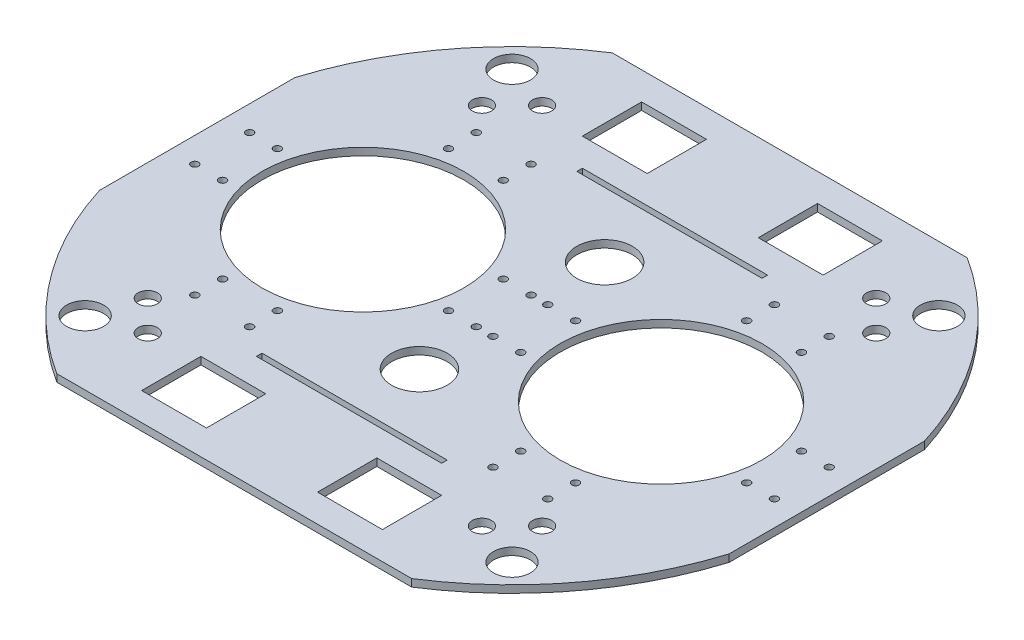
from build123d import *

# Parameters (mm, degrees)
SKETCH_1_R          = 178
EXTRUDE_1_DEPTH     = 4
SKETCH_2_R          = 10
SKETCH_2_R_2        = 5.2
CUT_EXTRUDE_1_DEPTH = 10
SKETCH_4_R          = 54.5
CUT_EXTRUDE_2_DEPTH = 10
SKETCH_5_R          = 2
CUT_EXTRUDE_3_DEPTH = 10
CUT_EXTRUDE_4_DEPTH = 10
SKETCH_11_W         = 100
SKETCH_11_H         = 3
CUT_EXTRUDE_5_DEPTH = 10
SKETCH_13_R         = 15
CUT_EXTRUDE_6_DEPTH = 10


with BuildPart() as part:
    # 草图1 → 凸台-拉伸1 (new body)
    with BuildSketch(Plane(origin=(0, 0, 0), x_dir=(1, 0, 0), z_dir=(0, 1, 0))):
        Circle(SKETCH_1_R)
    extrude(amount=EXTRUDE_1_DEPTH)

    # 草图2 → 切除-拉伸1 (cut)
    with BuildSketch(Plane(origin=(0, 4, 0), x_dir=(1, 0, 0), z_dir=(0, 1, 0))):
        with Locations((115.258405333, 115.258405333)):
            Circle(SKETCH_2_R)
        with Locations((-90.216925784, -106.480381752)):
            Circle(SKETCH_2_R_2)
        with Locations((-106.480381752, -90.216925784)):
            Circle(SKETCH_2_R_2)
        with Locations((115.258405333, -115.258405333)):
            Circle(SKETCH_2_R)
        with Locations((-115.258405333, -115.258405333)):
            Circle(SKETCH_2_R)
        with Locations((-115.258405333, 115.258405333)):
            Circle(SKETCH_2_R)
        with Locations((-90.216925784, 106.480381752)):
            Circle(SKETCH_2_R_2)
        with Locations((-106.480381752, 90.216925784)):
            Circle(SKETCH_2_R_2)
        with Locations((106.480381752, 90.216925784)):
            Circle(SKETCH_2_R_2)
        with Locations((90.216925784, 106.480381752)):
            Circle(SKETCH_2_R_2)
        with Locations((90.216925784, -106.480381752)):
            Circle(SKETCH_2_R_2)
        with Locations((106.480381752, -90.216925784)):
            Circle(SKETCH_2_R_2)
    extrude(amount=-CUT_EXTRUDE_1_DEPTH, mode=Mode.SUBTRACT)

    # 草图4 → 切除-拉伸2 (cut)
    with BuildSketch(Plane.XZ):
        with Locations((80.5, 0)):
            Circle(SKETCH_4_R)
        with Locations((-80.5, 0)):
            Circle(SKETCH_4_R)
    extrude(amount=-CUT_EXTRUDE_2_DEPTH, mode=Mode.SUBTRACT)

    # 草图5 → 切除-拉伸3 (cut)
    with BuildSketch(Plane(origin=(0, 4, 0), x_dir=(1, 0, 0), z_dir=(0, 1, 0))):
        with Locations((-19.5, -14.8)):
            Circle(SKETCH_5_R)
        with Locations((-4.5, -14.8)):
            Circle(SKETCH_5_R)
        with Locations((-4.5, 14.8)):
            Circle(SKETCH_5_R)
        with Locations((-19.5, 14.8)):
            Circle(SKETCH_5_R)
        with Locations((4.5, -14.8)):
            Circle(SKETCH_5_R)
        with Locations((19.5, -14.8)):
            Circle(SKETCH_5_R)
        with Locations((19.5, 14.8)):
            Circle(SKETCH_5_R)
        with Locations((4.5, 14.8)):
            Circle(SKETCH_5_R)
        with Locations((-65.7, -61)):
            Circle(SKETCH_5_R)
        with Locations((-65.7, -76)):
            Circle(SKETCH_5_R)
        with Locations((-95.3, -61)):
            Circle(SKETCH_5_R)
        with Locations((-95.3, -76)):
            Circle(SKETCH_5_R)
        with Locations((-141.5, -14.8)):
            Circle(SKETCH_5_R)
        with Locations((-156.5, -14.8)):
            Circle(SKETCH_5_R)
        with Locations((-141.5, 14.8)):
            Circle(SKETCH_5_R)
        with Locations((-156.5, 14.8)):
            Circle(SKETCH_5_R)
        with Locations((-95.3, 61)):
            Circle(SKETCH_5_R)
        with Locations((-95.3, 76)):
            Circle(SKETCH_5_R)
        with Locations((-65.7, 61)):
            Circle(SKETCH_5_R)
        with Locations((-65.7, 76)):
            Circle(SKETCH_5_R)
        with Locations((95.3, 76)):
            Circle(SKETCH_5_R)
        with Locations((95.3, 61)):
            Circle(SKETCH_5_R)
        with Locations((65.7, 76)):
            Circle(SKETCH_5_R)
        with Locations((65.7, 61)):
            Circle(SKETCH_5_R)
        with Locations((156.5, -14.8)):
            Circle(SKETCH_5_R)
        with Locations((141.5, -14.8)):
            Circle(SKETCH_5_R)
        with Locations((156.5, 14.8)):
            Circle(SKETCH_5_R)
        with Locations((141.5, 14.8)):
            Circle(SKETCH_5_R)
        with Locations((65.7, -76)):
            Circle(SKETCH_5_R)
        with Locations((65.7, -61)):
            Circle(SKETCH_5_R)
        with Locations((95.3, -76)):
            Circle(SKETCH_5_R)
        with Locations((95.3, -61)):
            Circle(SKETCH_5_R)
    extrude(amount=-CUT_EXTRUDE_3_DEPTH, mode=Mode.SUBTRACT)

    # 草图8 → 切除-拉伸4 (cut)
    with BuildSketch(Plane.XZ):
        with BuildLine():
            Line((95.833188406, 150), (0, 150))
            Line((0, 150), (-95.833188406, 150))
            ThreePointArc((-95.833188406, 150), (0, 178), (95.833188406, 150))
        make_face()
        with BuildLine():
            Line((170, 52.763623833), (170, 0))
            Line((170, 0), (170, -52.763623833))
            ThreePointArc((170, -52.763623833), (178, 0), (170, 52.763623833))
        make_face()
        with BuildLine():
            Line((0, -150), (-95.833188406, -150))
            ThreePointArc((-95.833188406, -150), (0, -178), (95.833188406, -150))
            Line((95.833188406, -150), (0, -150))
        make_face()
        with BuildLine():
            Line((-170, 0), (-170, -52.763623833))
            ThreePointArc((-170, -52.763623833), (-178, 0), (-170, 52.763623833))
            Line((-170, 52.763623833), (-170, 0))
        make_face()
    extrude(amount=-CUT_EXTRUDE_4_DEPTH, mode=Mode.SUBTRACT)

    # 草图11 → 切除-拉伸5 (cut)
    with BuildSketch(Plane.XZ):
        with Locations((0, -86.5)):
            Rectangle(SKETCH_11_W, SKETCH_11_H)
        Polygon((65, -135), (30, -135), (30, -119), (30, -103), (65, -103), align=None)
        Polygon((-65, -119), (-65, -103), (-30, -103), (-30, -119), (-30, -135), (-65, -135), align=None)
        with Locations((0, 86.5)):
            Rectangle(SKETCH_11_W, SKETCH_11_H)
        Polygon((-65, 119), (-65, 103), (-30, 103), (-30, 119), (-30, 135), (-65, 135), align=None)
        Polygon((65, 103), (65, 135), (30, 135), (30, 119), (30, 103), align=None)
    extrude(amount=-CUT_EXTRUDE_5_DEPTH, mode=Mode.SUBTRACT)

    # 草图13 → 切除-拉伸6 (cut)
    with BuildSketch(Plane.XZ):
        with Locations((0, -50)):
            Circle(SKETCH_13_R)
        with Locations((0, 50)):
            Circle(SKETCH_13_R)
    extrude(amount=-CUT_EXTRUDE_6_DEPTH, mode=Mode.SUBTRACT)


solid = part.part
